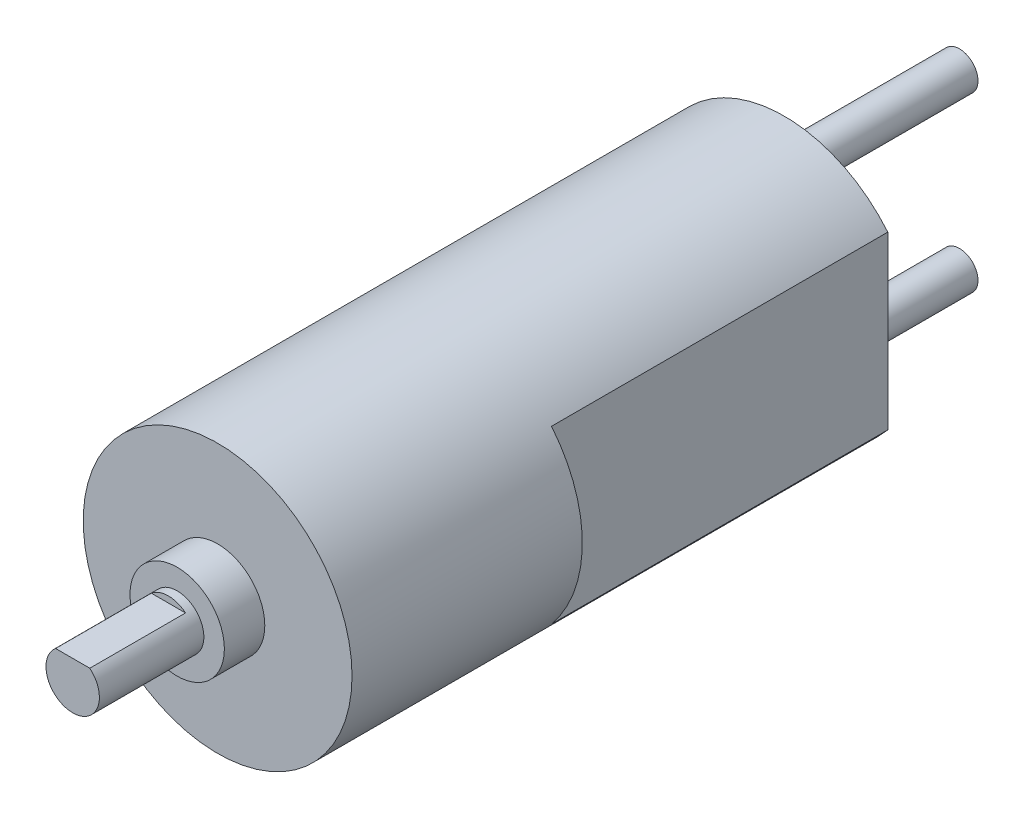
from build123d import *

# Parameters (mm, degrees)
SKETCH1_R           = 9.9695
BOSS_EXTRUDE1_DEPTH = 17.0815
BOSS_EXTRUDE2_DEPTH = 24.9428
SKETCH3_R           = 3.5
BOSS_EXTRUDE3_DEPTH = 3
SKETCH4_R           = 1.98
BOSS_EXTRUDE4_DEPTH = 7.75
CUT_EXTRUDE1_DEPTH  = 7.1
SKETCH6_R           = 3.01
BOSS_EXTRUDE5_DEPTH = 1.8
FILLET1_R           = 0.5
FILLET2_R           = 0.1
SKETCH7_R           = 1.375
BOSS_EXTRUDE6_DEPTH = 13


with BuildPart() as part:
    # Sketch1 → Boss-Extrude1 (new body)
    with BuildSketch(Plane.XY):
        Circle(SKETCH1_R)
    extrude(amount=BOSS_EXTRUDE1_DEPTH)

    # Sketch2 → Boss-Extrude2 (add)
    with BuildSketch(Plane(origin=(0, 0, 0), x_dir=(-1, 0, 0), z_dir=(0, 0, -1))):
        with BuildLine():
            Line((-7.6835, 6.352539492), (-7.6835, -6.352539492))
            ThreePointArc((-7.6835, -6.352539492), (0, -9.9695), (7.6835, -6.352539492))
            Line((7.6835, -6.352539492), (7.6835, 6.352539492))
            ThreePointArc((7.6835, 6.352539492), (0, 9.9695), (-7.6835, 6.352539492))
        make_face()
    extrude(amount=BOSS_EXTRUDE2_DEPTH)

    # Sketch3 → Boss-Extrude3 (add)
    with BuildSketch(Plane.XY.offset(17.0815)):
        Circle(SKETCH3_R)
    extrude(amount=BOSS_EXTRUDE3_DEPTH)

    # Sketch4 → Boss-Extrude4 (add)
    with BuildSketch(Plane.XY.offset(20.0815)):
        Circle(SKETCH4_R)
    extrude(amount=BOSS_EXTRUDE4_DEPTH)

    # Sketch5 → Cut-Extrude1 (cut)
    with BuildSketch(Plane.XY.offset(27.8315)):
        with BuildLine():
            Line((-1.268857754, 1.52), (1.268857754, 1.52))
            ThreePointArc((1.268857754, 1.52), (0, 1.98), (-1.268857754, 1.52))
        make_face()
    extrude(amount=-CUT_EXTRUDE1_DEPTH, mode=Mode.SUBTRACT)

    # Sketch6 → Boss-Extrude5 (add)
    with BuildSketch(Plane(origin=(0, 0, -24.9428), x_dir=(-1, 0, 0), z_dir=(0, 0, -1))):
        Circle(SKETCH6_R)
    extrude(amount=BOSS_EXTRUDE5_DEPTH)

    # Fillet1
    fillet1_edges = [part.edges().sort_by_distance(p)[0] for p in [
        (3.01, 0, -24.9428),
    ]]
    fillet(fillet1_edges, radius=FILLET1_R)

    # Fillet2
    fillet2_edges = [part.edges().sort_by_distance(p)[0] for p in [
        (3.01, 0, -26.7428),
    ]]
    fillet(fillet2_edges, radius=FILLET2_R)

    # Sketch7 → Boss-Extrude6 (add)
    with BuildSketch(Plane(origin=(0, 0, -24.9428), x_dir=(-1, 0, 0), z_dir=(0, 0, -1))):
        with Locations((0, 6.41)):
            Circle(SKETCH7_R)
        with Locations((0, -6.41)):
            Circle(SKETCH7_R)
    extrude(amount=BOSS_EXTRUDE6_DEPTH)


solid = part.part
